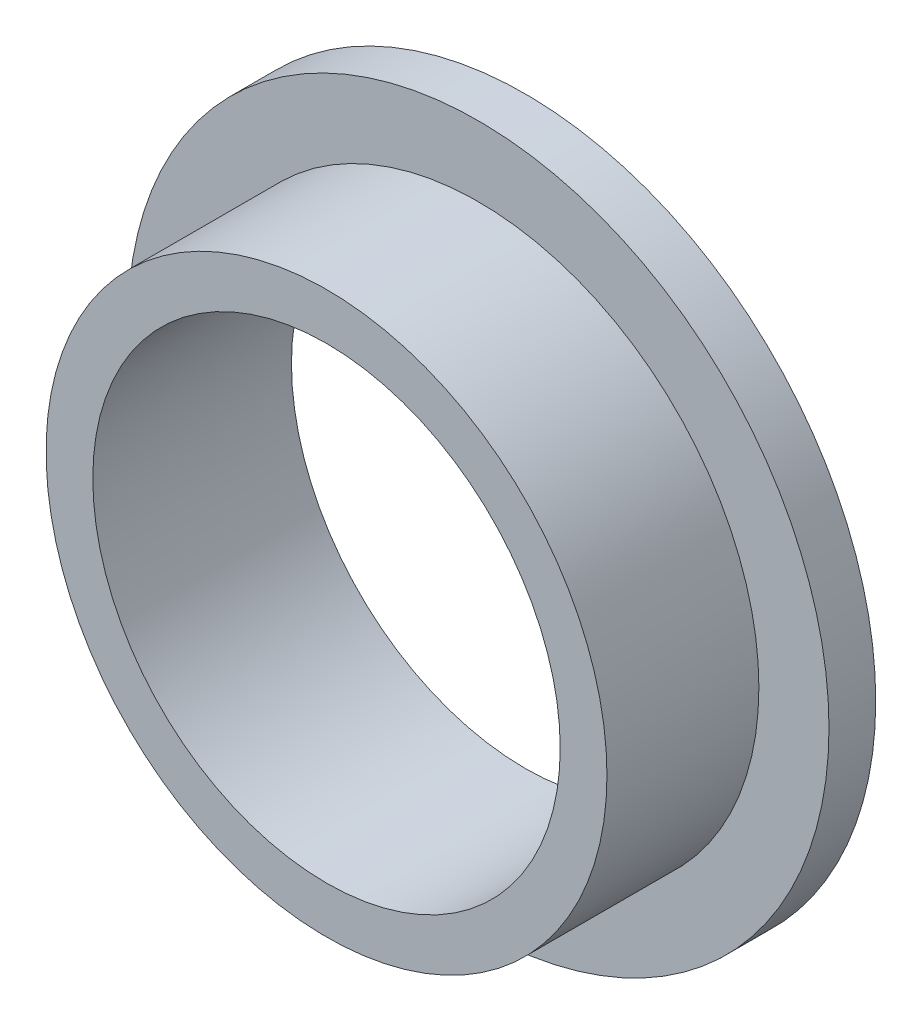
from build123d import *


with BuildPart() as part:
    # Sketch1 → Revolve1 (revolve)
    with BuildSketch(Plane(origin=(0, 0, 0), x_dir=(0, 0, -1), z_dir=(1, 0, 0))):
        Polygon((-25.5, 30), (0, 30), (0, 45), (-6, 45), (-6, 36), (-25.5, 36), align=None)
    revolve(axis=Axis((0, 0, 30.762711864), (0, 0, -1)))


solid = part.part
